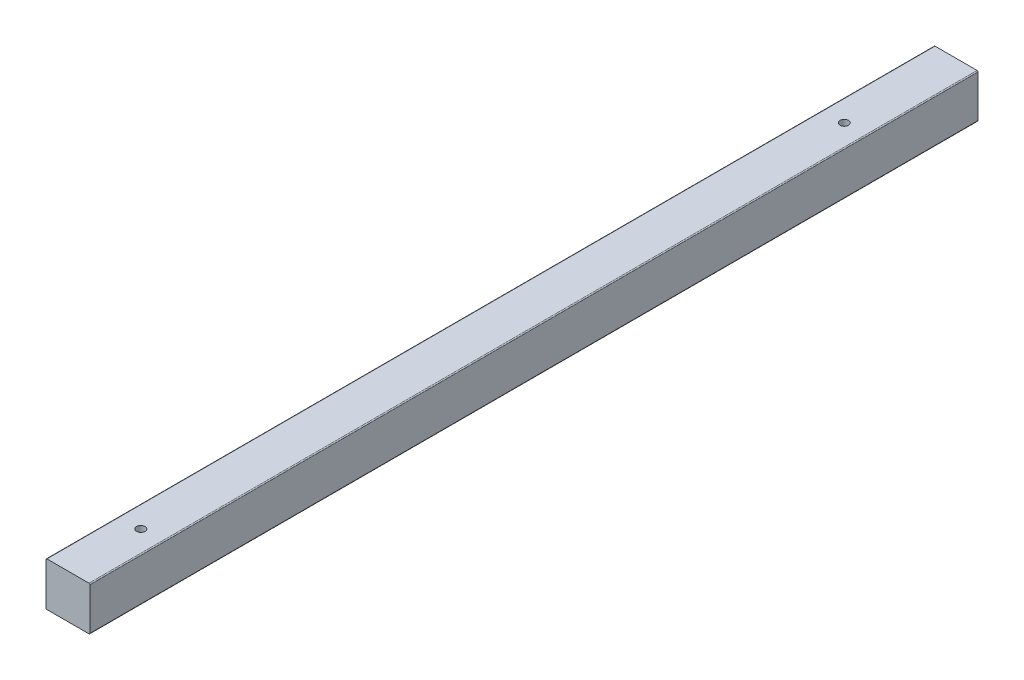
from build123d import *

# Parameters (mm, degrees)
SKETCH1_W           = 44
SKETCH1_H           = 44
BOSS_EXTRUDE1_DEPTH = 890
FILLET1_R           = 1
SKETCH2_R           = 14
CUT_EXTRUDE1_DEPTH  = 8
SKETCH3_R           = 4.25
CUT_EXTRUDE2_DEPTH  = 37


with BuildPart() as part:
    # Sketch1 → Boss-Extrude1 (new body)
    with BuildSketch(Plane.XY):
        with Locations((-22, 22)):
            Rectangle(SKETCH1_W, SKETCH1_H)
    extrude(amount=BOSS_EXTRUDE1_DEPTH)

    # Fillet1
    fillet1_edges = [part.edges().sort_by_distance(p)[0] for p in [
        (0, 0, 445),
        (-44, 0, 445),
        (-44, 44, 445),
        (0, 44, 445),
    ]]
    fillet(fillet1_edges, radius=FILLET1_R)

    # Sketch2 → Cut-Extrude1 (cut)
    with BuildSketch(Plane.XZ):
        with Locations((-22, 817)):
            Circle(SKETCH2_R)
        with Locations((-22, 112)):
            Circle(SKETCH2_R)
    extrude(amount=-CUT_EXTRUDE1_DEPTH, mode=Mode.SUBTRACT)

    # Sketch3 → Cut-Extrude2 (cut, through all)
    with BuildSketch(Plane.XZ.offset(-8)):
        with Locations((-22, 817)):
            Circle(SKETCH3_R)
        with Locations((-22, 112)):
            Circle(SKETCH3_R)
    extrude(amount=-CUT_EXTRUDE2_DEPTH, mode=Mode.SUBTRACT)


solid = part.part
